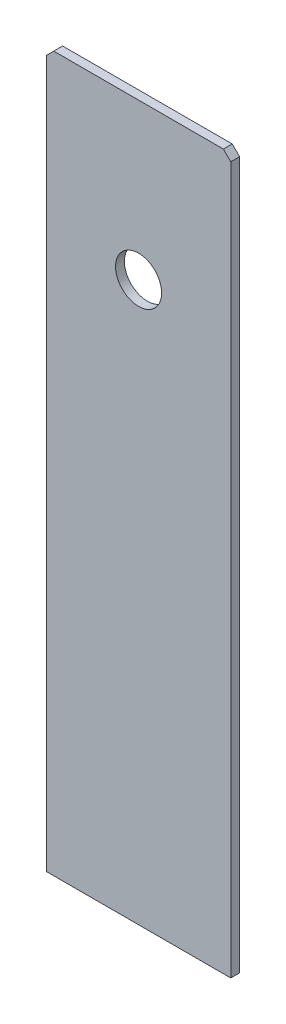
from build123d import *

# Parameters (mm, degrees)
SKETCH1_W           = 63.5
SKETCH1_H           = 245.9736
SKETCH1_R           = 7.9375
BOSS_EXTRUDE1_DEPTH = 3.048
CHAMFER1_SIZE       = 2.54


with BuildPart() as part:
    # Sketch1 → Boss-Extrude1 (new body)
    with BuildSketch(Plane.XY):
        with Locations((31.75, 122.9868)):
            Rectangle(SKETCH1_W, SKETCH1_H)
        with Locations((31.75, 192.3796)):
            Circle(SKETCH1_R, mode=Mode.SUBTRACT)
    extrude(amount=BOSS_EXTRUDE1_DEPTH)

    # Chamfer1
    chamfer1_edges = [part.edges().sort_by_distance(p)[0] for p in [
        (0, 245.9736, 1.524),
        (63.5, 245.9736, 1.524),
    ]]
    chamfer(chamfer1_edges, length=CHAMFER1_SIZE)


solid = part.part
